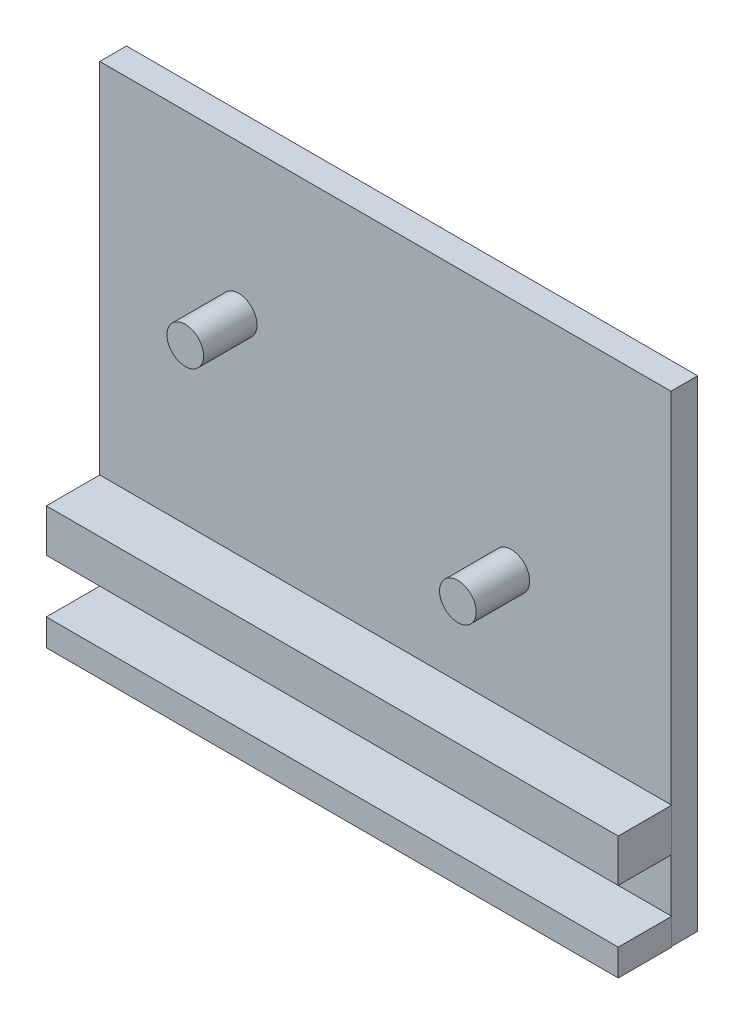
from build123d import *

# Parameters (mm, degrees)
SKETCH1_R             = 3.424139869
BOSS_EXTRUDE1_DEPTH   = 10
BOSS_EXTRUDE1_2_DEPTH = 10
SKETCH2_W             = 106.866754861
SKETCH2_H             = 90
BOSS_EXTRUDE2_DEPTH   = 5
SKETCH3_W             = 107
SKETCH3_H             = 5
BOSS_EXTRUDE3_DEPTH   = 10
SKETCH4_W             = 107
SKETCH4_H             = 8
BOSS_EXTRUDE4_DEPTH   = 10


with BuildPart() as part:
    # Sketch1 → Boss-Extrude1 (new body)
    with BuildSketch(Plane.XY):
        with Locations((-27.5, 9)):
            Circle(SKETCH1_R)
    extrude(amount=BOSS_EXTRUDE1_DEPTH)



with BuildPart() as body_2:
    # Sketch1 → Boss-Extrude1 2 (new body)
    with BuildSketch(Plane.XY):
        with Locations((23.5, -7)):
            Circle(SKETCH1_R)
    extrude(amount=BOSS_EXTRUDE1_2_DEPTH)


with BuildPart() as part_1:
    add(part.part)

    add(body_2.part)  # Boss-Extrude2 merges body 2
    # Sketch2 → Boss-Extrude2 (add)
    with BuildSketch(Plane(origin=(0, 0, 0), x_dir=(-1, 0, 0), z_dir=(0, 0, -1))):
        with Locations((0.066622569, -8)):
            Rectangle(SKETCH2_W, SKETCH2_H)
    extrude(amount=BOSS_EXTRUDE2_DEPTH)

    # Sketch3 → Boss-Extrude3 (add)
    with BuildSketch(Plane.XY):
        with Locations((0, -50.5)):
            Rectangle(SKETCH3_W, SKETCH3_H)
    extrude(amount=BOSS_EXTRUDE3_DEPTH)

    # Sketch4 → Boss-Extrude4 (add)
    with BuildSketch(Plane.XY):
        with Locations((0, -34)):
            Rectangle(SKETCH4_W, SKETCH4_H)
    extrude(amount=BOSS_EXTRUDE4_DEPTH)


solid = part_1.part
